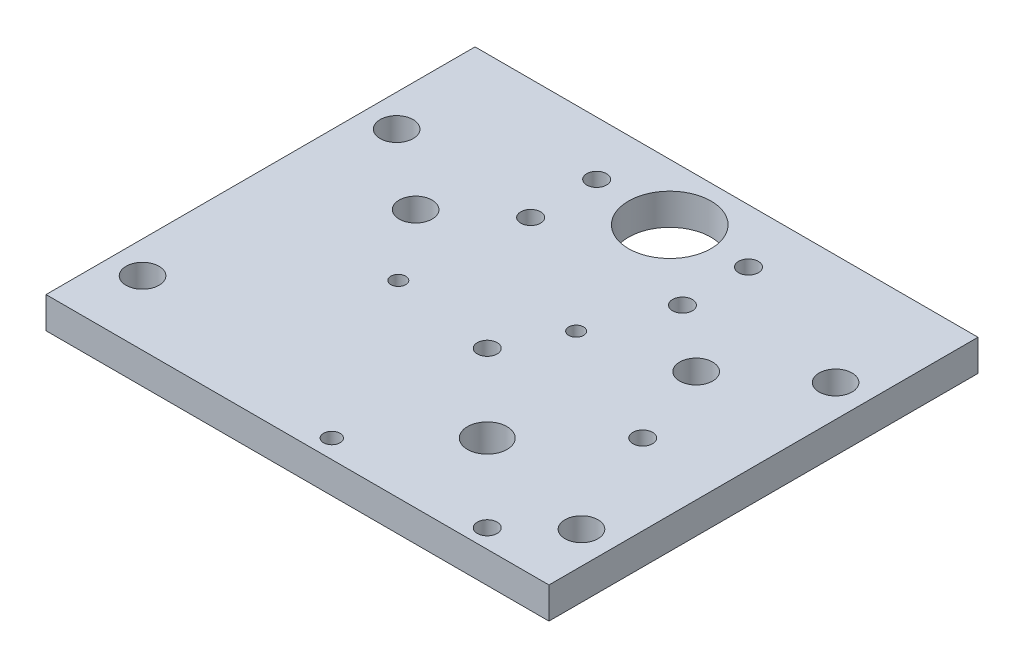
from build123d import *

# Parameters (mm, degrees)
SKETCH1_W           = 152.4
SKETCH1_H           = 130
BOSS_EXTRUDE1_DEPTH = 9.5
SKETCH2_R           = 2.5
SKETCH2_R_2         = 3
CUT_EXTRUDE1_DEPTH  = 10
SKETCH3_R           = 6
CUT_EXTRUDE2_DEPTH  = 10
SKETCH4_R           = 2.25
SKETCH4_R_2         = 12.5
CUT_EXTRUDE3_DEPTH  = 10.5
SKETCH5_R           = 3
CUT_EXTRUDE4_DEPTH  = 10.5
SKETCH6_R           = 5
CUT_EXTRUDE5_DEPTH  = 10.5


with BuildPart() as part:
    # Sketch1 → Boss-Extrude1 (new body)
    with BuildSketch(Plane(origin=(0, 0, 0), x_dir=(1, 0, 0), z_dir=(0, 1, 0))):
        Rectangle(SKETCH1_W, SKETCH1_H)
    extrude(amount=BOSS_EXTRUDE1_DEPTH)

    # Sketch2 → Cut-Extrude1 (cut)
    with BuildSketch(Plane(origin=(0, 0, 0), x_dir=(-1, 0, 0), z_dir=(0, -1, 0))):
        with Locations((-4.75, -59.35)):
            Circle(SKETCH2_R)
        with Locations((-51.85, -59.35)):
            Circle(SKETCH2_R_2)
        with Locations((-4.75, -12.25)):
            Circle(SKETCH2_R_2)
        with Locations((-51.85, -12.25)):
            Circle(SKETCH2_R_2)
    extrude(amount=-CUT_EXTRUDE1_DEPTH, mode=Mode.SUBTRACT)

    # Sketch3 → Cut-Extrude2 (cut)
    with BuildSketch(Plane(origin=(0, 9.5, 0), x_dir=(1, 0, 0), z_dir=(0, 1, 0))):
        with Locations((28.3, -35.8)):
            Circle(SKETCH3_R)
    extrude(amount=-CUT_EXTRUDE2_DEPTH, mode=Mode.SUBTRACT)

    # Sketch4 → Cut-Extrude3 (cut, through all)
    with BuildSketch(Plane(origin=(0, 9.5, 0), x_dir=(1, 0, 0), z_dir=(0, 1, 0))):
        with Locations((-26.534128982, -7.921988471)):
            Circle(SKETCH4_R)
        with Locations((13.721874775, 5.705342944)):
            Circle(SKETCH4_R)
        with Locations((0, 47.8)):
            Circle(SKETCH4_R_2)
    extrude(amount=-CUT_EXTRUDE3_DEPTH, mode=Mode.SUBTRACT)

    # Sketch5 → Cut-Extrude4 (cut, through all)
    with BuildSketch(Plane(origin=(0, 9.5, 0), x_dir=(1, 0, 0), z_dir=(0, 1, 0))):
        with Locations((23, 28.65)):
            Circle(SKETCH5_R)
        with Locations((-23, 28.65)):
            Circle(SKETCH5_R)
        with Locations((23, 48.65)):
            Circle(SKETCH5_R)
        with Locations((-23, 48.65)):
            Circle(SKETCH5_R)
    extrude(amount=-CUT_EXTRUDE4_DEPTH, mode=Mode.SUBTRACT)

    # Sketch6 → Cut-Extrude5 (cut, through all)
    with BuildSketch(Plane(origin=(0, 9.5, 0), x_dir=(1, 0, 0), z_dir=(0, 1, 0))):
        with Locations((-66.5, 31.55)):
            Circle(SKETCH6_R)
        with Locations((-66.5, -45.45)):
            Circle(SKETCH6_R)
        with Locations((66.5, -45.45)):
            Circle(SKETCH6_R)
        with Locations((66.5, 31.55)):
            Circle(SKETCH6_R)
        with Locations((-42.5, 13.3)):
            Circle(SKETCH6_R)
        with Locations((42.5, 13.3)):
            Circle(SKETCH6_R)
    extrude(amount=-CUT_EXTRUDE5_DEPTH, mode=Mode.SUBTRACT)


solid = part.part
